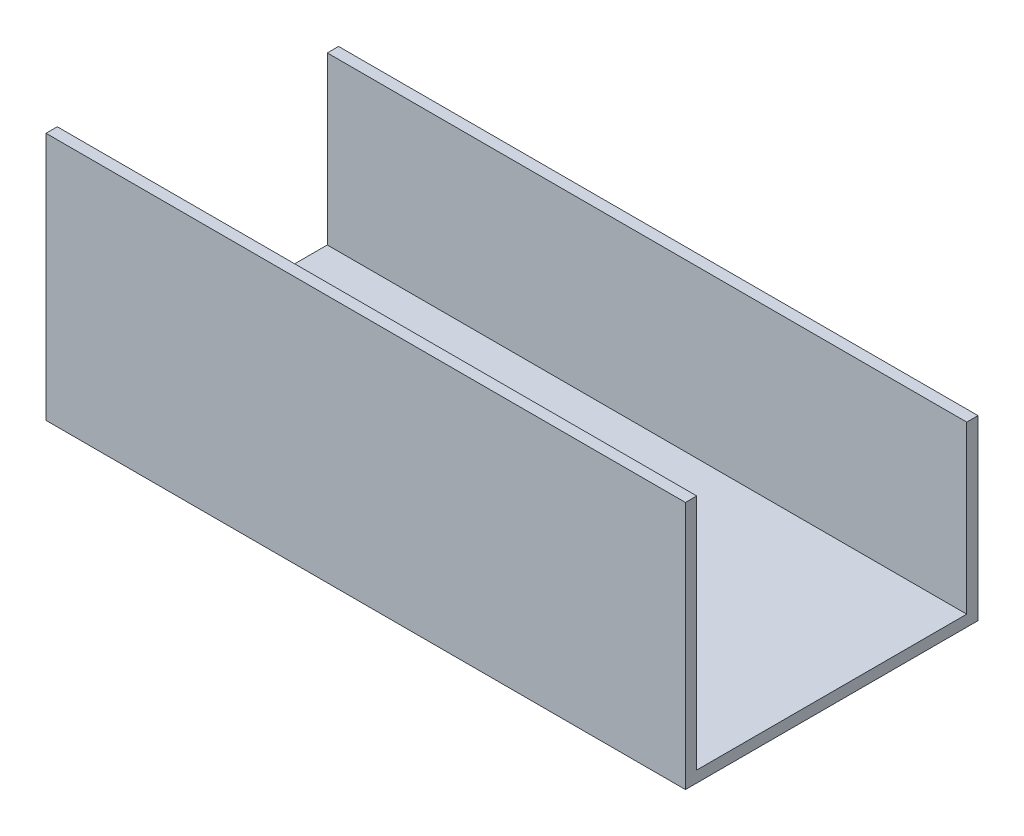
from build123d import *

# Parameters (mm, degrees)
BOSS_EXTRUDE1_DEPTH = 180


with BuildPart() as part:
    # Sketch1 → Boss-Extrude1 (new body)
    with BuildSketch(Plane(origin=(0, 0, 0), x_dir=(0, 0, -1), z_dir=(1, 0, 0))):
        Polygon((0, 0), (0, -66.82), (76, -66.82), (76, -20), (79.175, -20), (79.175, -70), (-3.18, -70), (-3.18, 0), align=None)
    extrude(amount=BOSS_EXTRUDE1_DEPTH)


solid = part.part
